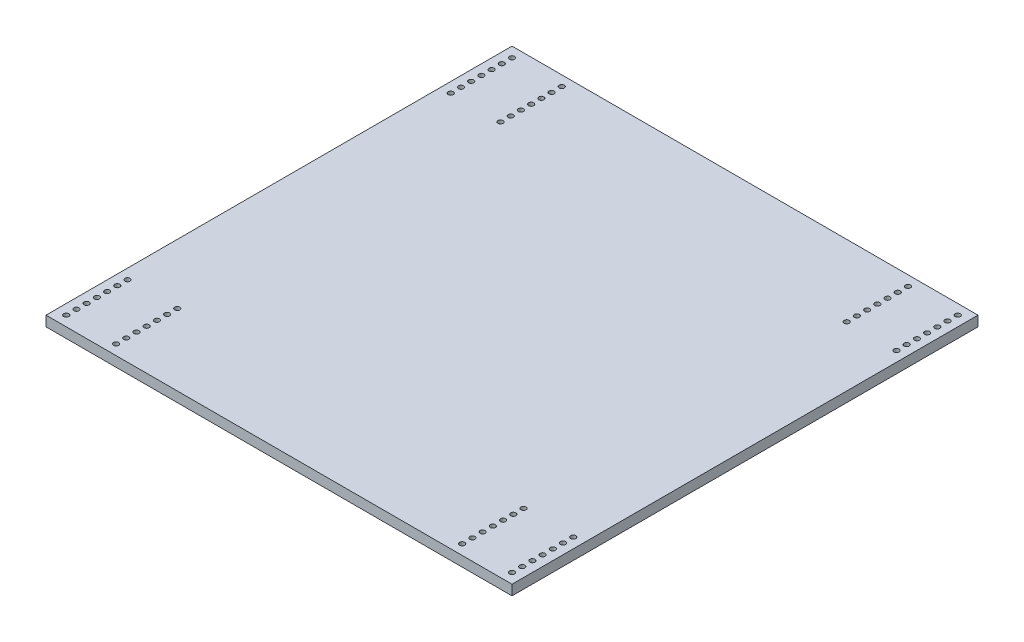
from build123d import *

# Parameters (mm, degrees)
SKETCH1_W           = 292.1
SKETCH1_H           = 292.1
BOSS_EXTRUDE1_DEPTH = 6.35
SKETCH2_R           = 1.6
CUT_EXTRUDE2_DEPTH  = 7.35


with BuildPart() as part:
    # Sketch1 → Boss-Extrude1 (new body)
    with BuildSketch(Plane(origin=(0, 0, 0), x_dir=(1, 0, 0), z_dir=(0, 1, 0))):
        Rectangle(SKETCH1_W, SKETCH1_H)
    extrude(amount=BOSS_EXTRUDE1_DEPTH)

    # Sketch2 → Cut-Extrude2 (cut, through all)
    with BuildSketch(Plane(origin=(0, 6.35, 0), x_dir=(1, 0, 0), z_dir=(0, 1, 0))):
        with Locations((-139.7, -139.7)):
            Circle(SKETCH2_R)
        with Locations((-139.7, -133.3)):
            Circle(SKETCH2_R)
        with Locations((-139.7, -126.9)):
            Circle(SKETCH2_R)
        with Locations((-139.7, -120.5)):
            Circle(SKETCH2_R)
        with Locations((-139.7, -114.1)):
            Circle(SKETCH2_R)
        with Locations((-139.7, -107.7)):
            Circle(SKETCH2_R)
        with Locations((-139.7, -101.3)):
            Circle(SKETCH2_R)
        with Locations((-139.7, 101.3)):
            Circle(SKETCH2_R)
        with Locations((-139.7, 107.7)):
            Circle(SKETCH2_R)
        with Locations((-139.7, 114.1)):
            Circle(SKETCH2_R)
        with Locations((-139.7, 120.5)):
            Circle(SKETCH2_R)
        with Locations((-139.7, 126.9)):
            Circle(SKETCH2_R)
        with Locations((-139.7, 133.3)):
            Circle(SKETCH2_R)
        with Locations((-139.7, 139.7)):
            Circle(SKETCH2_R)
        with Locations((-108.5, 139.7)):
            Circle(SKETCH2_R)
        with Locations((-108.5, 133.3)):
            Circle(SKETCH2_R)
        with Locations((-108.5, 126.9)):
            Circle(SKETCH2_R)
        with Locations((-108.5, 120.5)):
            Circle(SKETCH2_R)
        with Locations((-108.5, 114.1)):
            Circle(SKETCH2_R)
        with Locations((-108.5, 107.7)):
            Circle(SKETCH2_R)
        with Locations((-108.5, 101.3)):
            Circle(SKETCH2_R)
        with Locations((-108.5, -101.3)):
            Circle(SKETCH2_R)
        with Locations((-108.5, -107.7)):
            Circle(SKETCH2_R)
        with Locations((-108.5, -114.1)):
            Circle(SKETCH2_R)
        with Locations((-108.5, -120.5)):
            Circle(SKETCH2_R)
        with Locations((-108.5, -126.9)):
            Circle(SKETCH2_R)
        with Locations((-108.5, -133.3)):
            Circle(SKETCH2_R)
        with Locations((-108.5, -139.7)):
            Circle(SKETCH2_R)
        with Locations((108.5, -139.7)):
            Circle(SKETCH2_R)
        with Locations((108.5, -133.3)):
            Circle(SKETCH2_R)
        with Locations((108.5, -126.9)):
            Circle(SKETCH2_R)
        with Locations((108.5, -120.5)):
            Circle(SKETCH2_R)
        with Locations((108.5, -114.1)):
            Circle(SKETCH2_R)
        with Locations((108.5, -107.7)):
            Circle(SKETCH2_R)
        with Locations((108.5, -101.3)):
            Circle(SKETCH2_R)
        with Locations((108.5, 101.3)):
            Circle(SKETCH2_R)
        with Locations((108.5, 107.7)):
            Circle(SKETCH2_R)
        with Locations((108.5, 114.1)):
            Circle(SKETCH2_R)
        with Locations((108.5, 120.5)):
            Circle(SKETCH2_R)
        with Locations((108.5, 126.9)):
            Circle(SKETCH2_R)
        with Locations((108.5, 133.3)):
            Circle(SKETCH2_R)
        with Locations((108.5, 139.7)):
            Circle(SKETCH2_R)
        with Locations((139.7, 139.7)):
            Circle(SKETCH2_R)
        with Locations((139.7, 133.3)):
            Circle(SKETCH2_R)
        with Locations((139.7, 126.9)):
            Circle(SKETCH2_R)
        with Locations((139.7, 120.5)):
            Circle(SKETCH2_R)
        with Locations((139.7, 114.1)):
            Circle(SKETCH2_R)
        with Locations((139.7, 107.7)):
            Circle(SKETCH2_R)
        with Locations((139.7, 101.3)):
            Circle(SKETCH2_R)
        with Locations((139.7, -101.3)):
            Circle(SKETCH2_R)
        with Locations((139.7, -107.7)):
            Circle(SKETCH2_R)
        with Locations((139.7, -114.1)):
            Circle(SKETCH2_R)
        with Locations((139.7, -120.5)):
            Circle(SKETCH2_R)
        with Locations((139.7, -126.9)):
            Circle(SKETCH2_R)
        with Locations((139.7, -133.3)):
            Circle(SKETCH2_R)
        with Locations((139.7, -139.7)):
            Circle(SKETCH2_R)
    extrude(amount=-CUT_EXTRUDE2_DEPTH, mode=Mode.SUBTRACT)


solid = part.part
